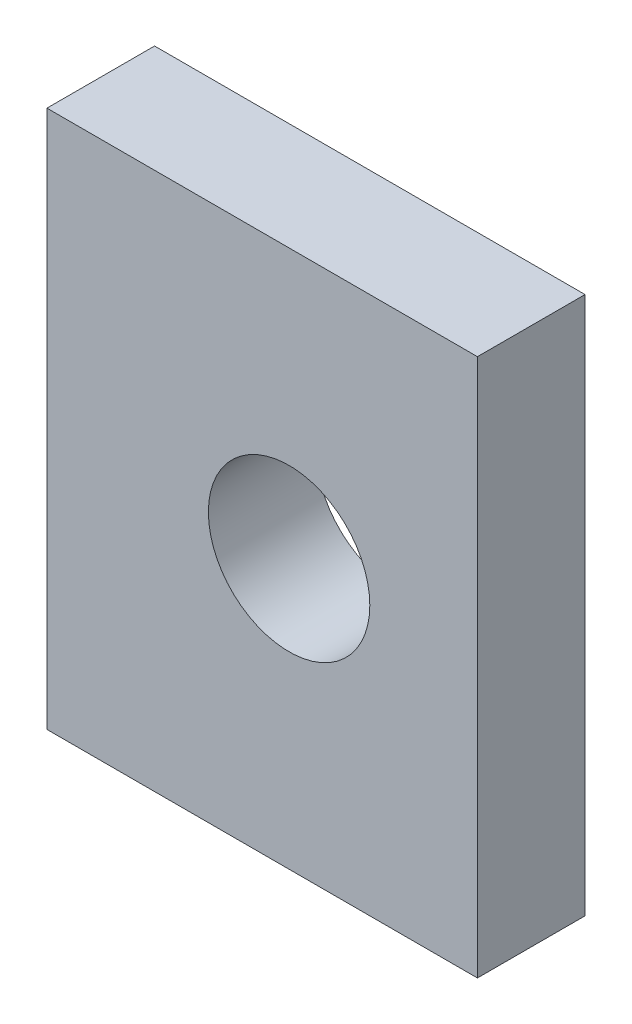
from build123d import *

# Parameters (mm, degrees)
SKETCH1_W           = 8
SKETCH1_H           = 10
SKETCH1_R           = 1.5
BOSS_EXTRUDE1_DEPTH = 2


with BuildPart() as part:
    # Sketch1 → Boss-Extrude1 (new body)
    with BuildSketch(Plane.XY):
        with Locations((4, 5)):
            Rectangle(SKETCH1_W, SKETCH1_H)
        with Locations((4.5, 5)):
            Circle(SKETCH1_R, mode=Mode.SUBTRACT)
    extrude(amount=BOSS_EXTRUDE1_DEPTH)


solid = part.part
